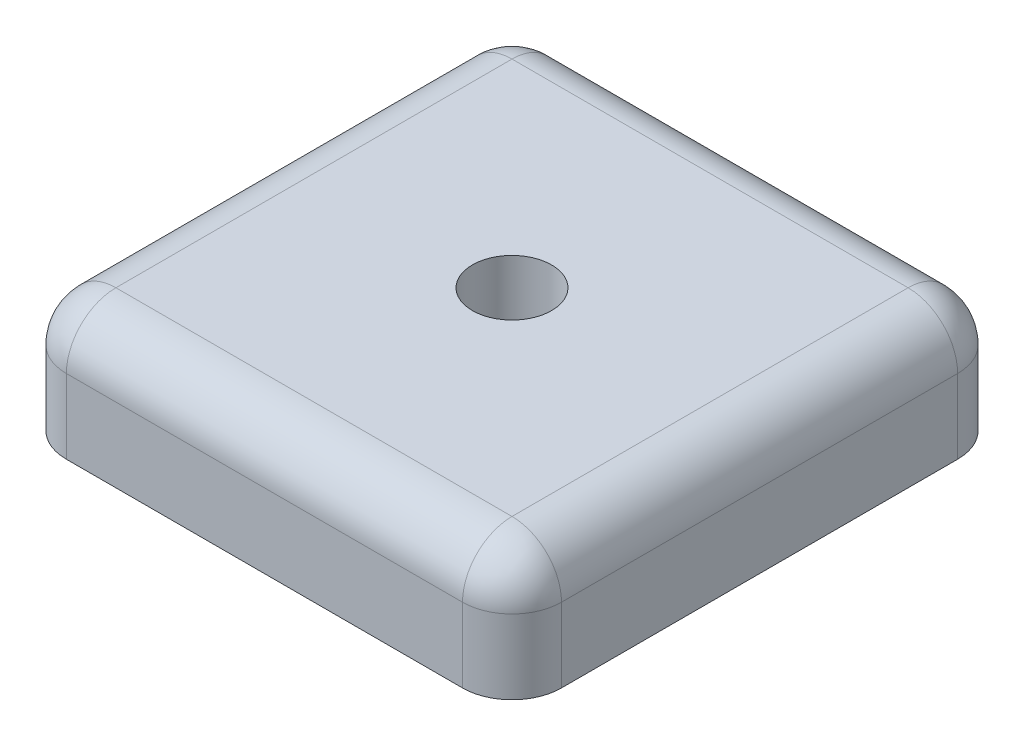
from build123d import *

# Parameters (mm, degrees)
SKETCH2_W           = 20
SKETCH2_H           = 20
BOSS_EXTRUDE1_DEPTH = 5
SKETCH3_R           = 1.6
CUT_EXTRUDE1_DEPTH  = 6
FILLET1_R           = 2


with BuildPart() as part:
    # Sketch2 → Boss-Extrude1 (new body)
    with BuildSketch(Plane(origin=(0, 0, 0), x_dir=(1, 0, 0), z_dir=(0, 1, 0))):
        with Locations((10, 10)):
            Rectangle(SKETCH2_W, SKETCH2_H)
    extrude(amount=BOSS_EXTRUDE1_DEPTH)

    # Sketch3 → Cut-Extrude1 (cut, through all)
    with BuildSketch(Plane(origin=(0, 5, 0), x_dir=(1, 0, 0), z_dir=(0, 1, 0))):
        with Locations((10, 10)):
            Circle(SKETCH3_R)
    extrude(amount=-CUT_EXTRUDE1_DEPTH, mode=Mode.SUBTRACT)

    # Fillet1
    fillet1_edges = [part.edges().sort_by_distance(p)[0] for p in [
        (10, 5, -20),
        (0, 5, -10),
        (10, 5, 0),
        (0, 2.5, 0),
        (0, 2.5, -20),
        (20, 2.5, -20),
        (20, 2.5, 0),
        (20, 5, -10),
    ]]
    fillet(fillet1_edges, radius=FILLET1_R)


solid = part.part
